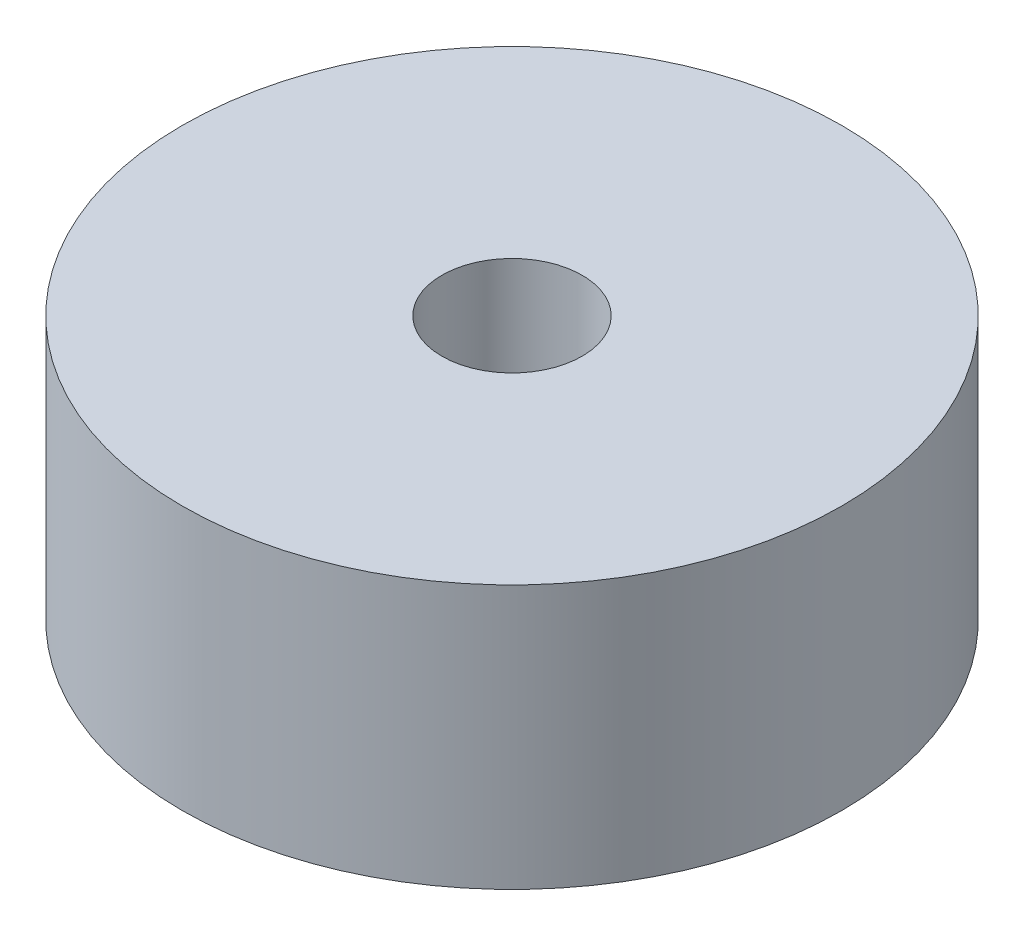
from build123d import *

# Parameters (mm, degrees)
SKETCH1_R           = 7.9375
SKETCH1_R_2         = 1.6891
BOSS_EXTRUDE1_DEPTH = 6.35


with BuildPart() as part:
    # Sketch1 → Boss-Extrude1 (new body)
    with BuildSketch(Plane(origin=(0, 0, 0), x_dir=(1, 0, 0), z_dir=(0, 1, 0))):
        Circle(SKETCH1_R)
        Circle(SKETCH1_R_2, mode=Mode.SUBTRACT)
    extrude(amount=BOSS_EXTRUDE1_DEPTH)


solid = part.part
